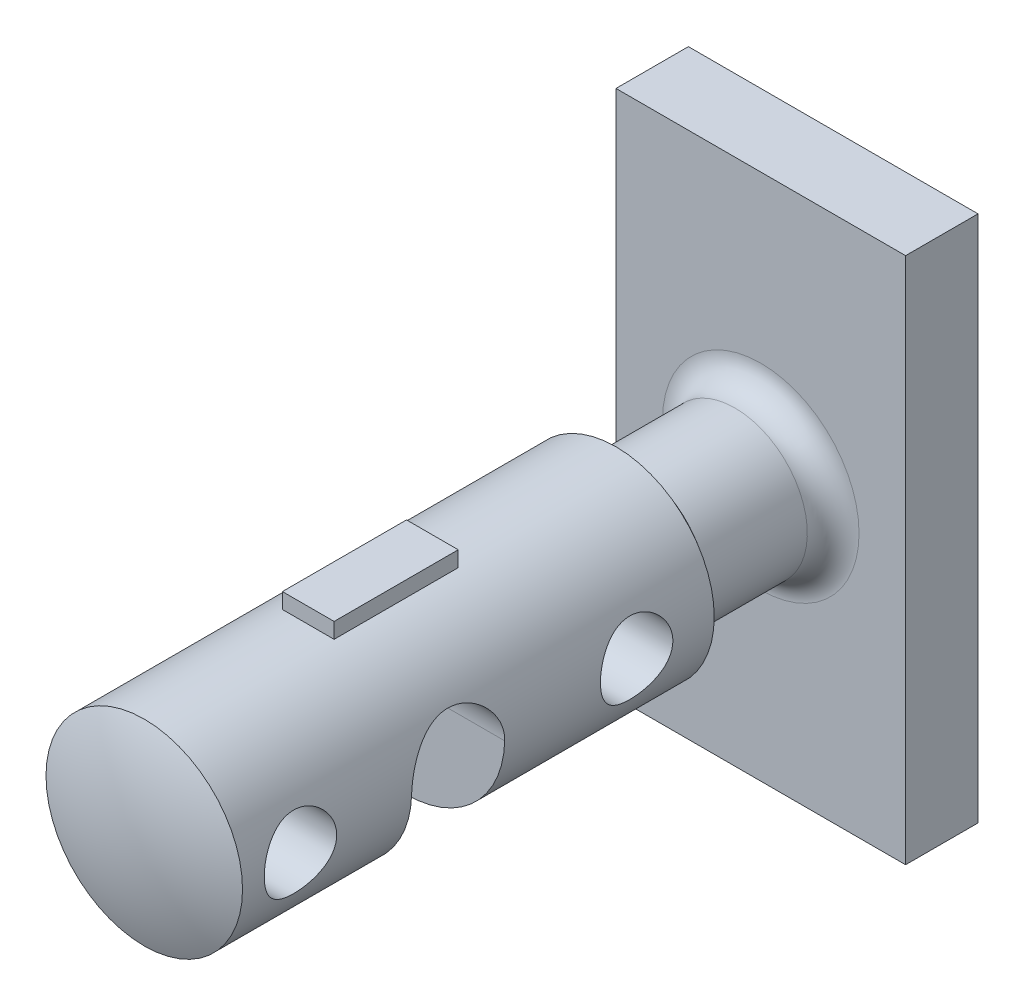
from build123d import *

# Parameters (mm, degrees)
SKETCH2_W           = 112
SKETCH2_H           = 28
BOSS_EXTRUDE1_DEPTH = 102
SKETCH7_R           = 14
CUT_EXTRUDE1_DEPTH  = 102
SKETCH8_W           = 48
SKETCH8_H           = 6
BOSS_EXTRUDE3_DEPTH = 10
CUT_EXTRUDE2_DEPTH  = 62
FILLET5_R           = 10


with BuildPart() as part:
    # Sketch2 → Boss-Extrude1 (new body, symmetric)
    with BuildSketch(Plane(origin=(0, 0, 0), x_dir=(1, 0, 0), z_dir=(0, 1, 0))):
        with Locations((0, 14)):
            Rectangle(SKETCH2_W, SKETCH2_H)
    extrude(amount=BOSS_EXTRUDE1_DEPTH, both=True)

    # Sketch6 → Revolve2 (revolve)
    with BuildSketch(Plane(origin=(0, 0, 0), x_dir=(0, 0, -1), z_dir=(1, 0, 0))):
        with BuildLine():
            Line((0, -28), (-48.804519097, -28))
            Line((-48.804519097, -28), (-56, -38))
            Line((-56, -38), (-238.413768212, -38))
            ThreePointArc((-238.413768212, -38), (-244.084912572, -19.374925243), (-246, 0))
            Line((-246, 0), (-147.034469102, 0))
            Line((-147.034469102, 0), (0, 0))
            Line((0, 0), (0, -28))
        make_face()
    revolve(axis=Axis((0, 0, 0), (0, 0, 1)))

    # Sketch7 → Cut-Extrude1 (cut, symmetric)
    with BuildSketch(Plane(origin=(0, 0, 0), x_dir=(0, 0, -1), z_dir=(1, 0, 0))):
        with Locations((-216, 0)):
            Circle(SKETCH7_R)
        with Locations((-86, 0)):
            Circle(SKETCH7_R)
    extrude(amount=CUT_EXTRUDE1_DEPTH, both=True, mode=Mode.SUBTRACT)

    # Sketch11 → Cut-Extrude2 (cut, symmetric)
    with BuildSketch(Plane(origin=(0, 0, 0), x_dir=(0, 0, -1), z_dir=(1, 0, 0))):
        with BuildLine():
            Line((-173.006418676, -1), (-173.006418676, -59.703789586))
            Line((-173.006418676, -59.703789586), (-137.006418676, -59.703789586))
            Line((-137.006418676, -59.703789586), (-137.006418676, -1))
            ThreePointArc((-137.006418676, -1), (-155.006418676, 17), (-173.006418676, -1))
        make_face()
    extrude(amount=CUT_EXTRUDE2_DEPTH, both=True, mode=Mode.SUBTRACT)

    # Fillet5
    fillet5_edges = [part.edges().sort_by_distance(p)[0] for p in [
        (0, 28, 0),
    ]]
    fillet(fillet5_edges, radius=FILLET5_R)


with BuildPart() as body_2:
    # Sketch8 → Boss-Extrude3 (new body, symmetric)
    with BuildSketch(Plane(origin=(0, 0, 0), x_dir=(0, 0, -1), z_dir=(1, 0, 0))):
        with Locations((-151, 41)):
            Rectangle(SKETCH8_W, SKETCH8_H)
    extrude(amount=BOSS_EXTRUDE3_DEPTH, both=True)


solid = Compound([part.part, body_2.part])
